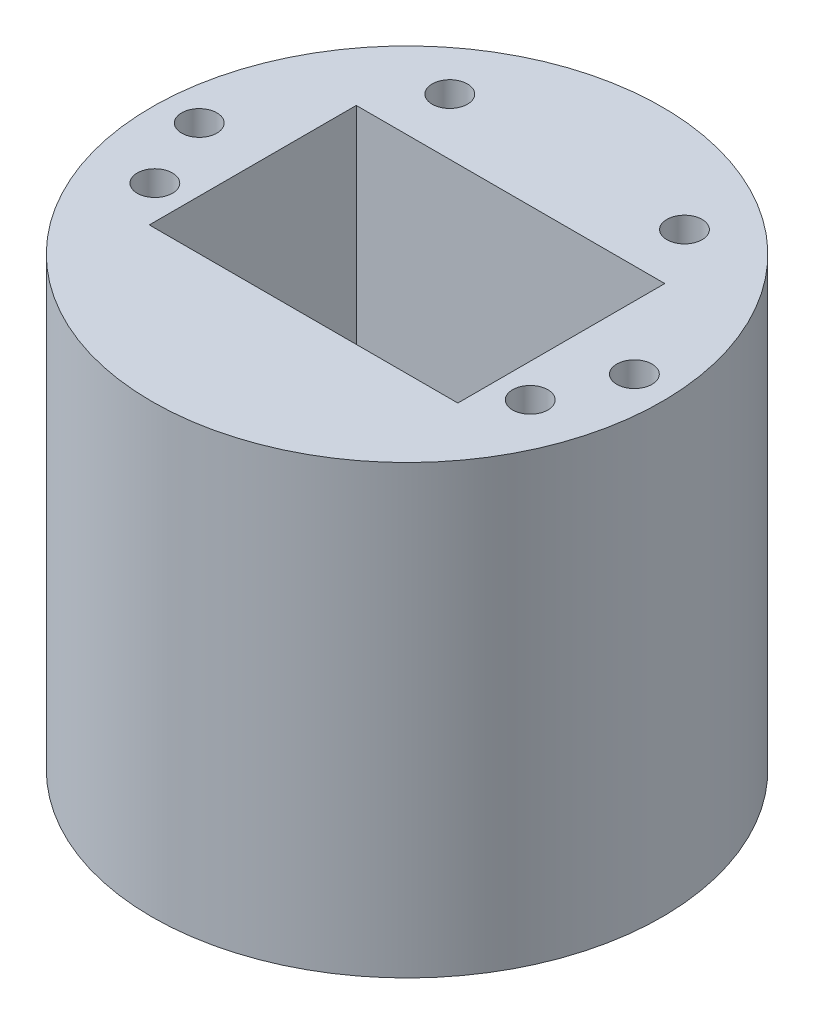
from build123d import *

# Parameters (mm, degrees)
SKETCH1_R           = 50.292
SKETCH1_R_2         = 3.475
BOSS_EXTRUDE1_DEPTH = 88
SKETCH2_W           = 60.822109288
SKETCH2_H           = 40.800022246
CUT_EXTRUDE1_DEPTH  = 68.04
SKETCH3_W           = 49.01906667
SKETCH3_H           = 20.847628368
CUT_EXTRUDE2_DEPTH  = 12


with BuildPart() as part:
    # Sketch1 → Boss-Extrude1 (new body)
    with BuildSketch(Plane(origin=(0, 0, 0), x_dir=(1, 0, 0), z_dir=(0, 1, 0))):
        Circle(SKETCH1_R)
        with Locations((42.886820356, 1.924977859)):
            Circle(SKETCH1_R_2, mode=Mode.SUBTRACT)
        with Locations((-42.886820356, 1.924977859)):
            Circle(SKETCH1_R_2, mode=Mode.SUBTRACT)
        with Locations((-37.000474826, -12.718618748)):
            Circle(SKETCH1_R_2, mode=Mode.SUBTRACT)
        with Locations((-23.129730363, 31.556520301)):
            Circle(SKETCH1_R_2, mode=Mode.SUBTRACT)
        with Locations((37.000474826, -12.718618748)):
            Circle(SKETCH1_R_2, mode=Mode.SUBTRACT)
        with Locations((23.129730363, 31.556520301)):
            Circle(SKETCH1_R_2, mode=Mode.SUBTRACT)
    extrude(amount=BOSS_EXTRUDE1_DEPTH)

    # Sketch2 → Cut-Extrude1 (cut)
    with BuildSketch(Plane(origin=(0, 88, 0), x_dir=(1, 0, 0), z_dir=(0, 1, 0))):
        Rectangle(SKETCH2_W, SKETCH2_H)
    extrude(amount=-CUT_EXTRUDE1_DEPTH, mode=Mode.SUBTRACT)

    # Sketch3 → Cut-Extrude2 (cut)
    with BuildSketch(Plane(origin=(0, 0, 0), x_dir=(-1, 0, 0), z_dir=(0, -1, 0))):
        Rectangle(SKETCH3_W, SKETCH3_H)
    extrude(amount=-CUT_EXTRUDE2_DEPTH, mode=Mode.SUBTRACT)


solid = part.part
